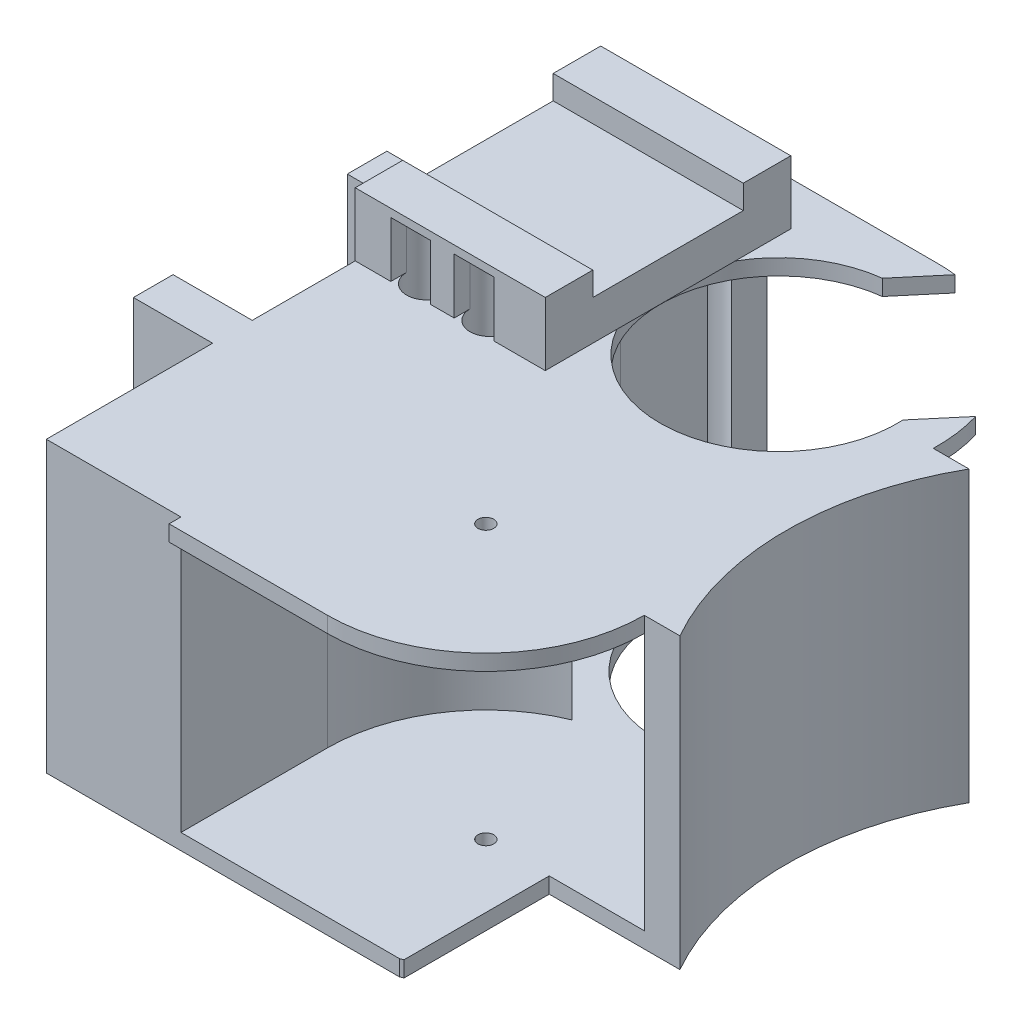
from build123d import *

# Parameters (mm, degrees)
SKETCH1_R                = 2
SKETCH1_R_2              = 1
BOSS_EXTRUDE18_DEPTH     = 34.5
CUT_EXTRUDE16_DEPTH      = 32.5
BOSS_EXTRUDE21_DEPTH     = 2
SKETCH9_R                = 2
BOSS_EXTRUDE22_DEPTH     = 34.5
SKETCH10_R               = 2
BOSS_EXTRUDE23_DEPTH     = 34.5
SKETCH11_R               = 2
CUT_EXTRUDE17_DEPTH      = 34.5
SKETCH12_W               = 24
SKETCH12_H               = 27
BOSS_EXTRUDE24_DEPTH     = 8
SKETCH13_W               = 24
SKETCH13_H               = 19
CUT_EXTRUDE18_DEPTH      = 3
SKETCH16_R               = 2.5
CUT_EXTRUDE21_DEPTH      = 41.5
SKETCH20_R               = 2.5
CUT_EXTRUDE22_DEPTH      = 41.5
SKETCH21_R               = 2.5
CUT_EXTRUDE23_DEPTH      = 41.5
SKETCH22_R               = 2.5
CUT_EXTRUDE24_DEPTH      = 41.5
BOSS_EXTRUDE25_DEPTH     = 2
BOSS_EXTRUDE26_DEPTH     = 2
SKETCH27_R               = 1
CUT_EXTRUDE27_DEPTH      = 5
SKETCH28_R               = 1
CUT_EXTRUDE28_DEPTH      = 5
SKETCH29_R               = 15
CUT_EXTRUDE29_DEPTH      = 2
SKETCH30_R               = 1
CUT_EXTRUDE30_DEPTH      = 2
CUT_EXTRUDE31_DEPTH      = 104.309002512
CUT_EXTRUDE31_DEPTH_BACK = 10
SKETCH32_R               = 2.5
SKETCH32_R_2             = 1
BOSS_EXTRUDE28_DEPTH     = 2
CUT_EXTRUDE32_DEPTH      = 2
SKETCH35_R               = 15
CUT_EXTRUDE33_DEPTH      = 2
BOSS_EXTRUDE30_START     = -2
SKETCH36_R               = 2.5
BOSS_EXTRUDE30_DEPTH     = 2
CUT_EXTRUDE40_START      = -2
CUT_EXTRUDE40_DEPTH      = 2
SKETCH39_R               = 2.5
CUT_EXTRUDE41_DEPTH      = 2
CUT_EXTRUDE42_START      = -2
CUT_EXTRUDE42_DEPTH      = 2
SKETCH42_R               = 1
BOSS_EXTRUDE31_DEPTH     = 5
SKETCH43_R               = 1
CUT_EXTRUDE44_DEPTH      = 5
SKETCH46_R               = 1
BOSS_EXTRUDE32_DEPTH     = 5
SKETCH47_R               = 1
CUT_EXTRUDE45_DEPTH      = 5
SKETCH48_R               = 1
BOSS_EXTRUDE33_DEPTH     = 5
SKETCH49_R               = 1
CUT_EXTRUDE46_DEPTH      = 5
SKETCH50_R               = 1
BOSS_EXTRUDE34_DEPTH     = 5
SKETCH51_R               = 1
CUT_EXTRUDE47_DEPTH      = 5


with BuildPart() as part:
    # Sketch1 → Boss-Extrude18 (new body)
    with BuildSketch(Plane(origin=(0, 0, 0), x_dir=(1, 0, 0), z_dir=(0, 1, 0))):
        with BuildLine():
            Line((0, 0), (17, 0))
            Line((17, 0), (17, 18.5))
            ThreePointArc((17, 18.5), (20.386950287, 29.635824138), (29.400657923, 37))
            ThreePointArc((29.400657923, 37), (20.386950287, 44.364175862), (17, 55.5))
            Line((17, 55.5), (17, 66.5))
            ThreePointArc((17, 66.5), (12.5, 68), (17, 69.5))
            Line((17, 69.5), (17, 74))
            Line((17, 74), (0, 74))
            Line((0, 74), (0, 53))
            Line((0, 53), (-10, 53))
            Line((-10, 53), (-10, 48))
            Line((-10, 48), (0, 48))
            Line((0, 48), (0, 26))
            Line((0, 26), (-10, 26))
            Line((-10, 26), (-10, 21))
            Line((-10, 21), (0, 21))
            Line((0, 21), (0, 0))
        make_face()
        with Locations(Location((7, 40, 0), (0, 0, 270))):
            Circle(SKETCH1_R, mode=Mode.SUBTRACT)
        with Locations(Location((15, 40, 0), (0, 0, 270))):
            Circle(SKETCH1_R, mode=Mode.SUBTRACT)
        with Locations(Location((7, 68, 0), (0, 0, 270))):
            Circle(SKETCH1_R, mode=Mode.SUBTRACT)
        with BuildLine():
            ThreePointArc((44.599342077, 37), (53.613049713, 29.635824138), (57, 18.5))
            Line((57, 18.5), (61.5, 18.5))
            ThreePointArc((61.5, 18.5), (56.685982974, 36.75), (61.5, 55))
            Line((61.5, 55), (56.993749023, 55))
            ThreePointArc((56.993749023, 55), (53.472542885, 44.157366669), (44.599342077, 37))
        make_face()
        with BuildLine():
            ThreePointArc((44.599342077, 0), (44.800132537, 0.083759004), (45, 0.16969722))
            Line((45, 0.16969722), (45, 18.5))
            Line((45, 18.5), (57, 18.5))
            ThreePointArc((57, 18.5), (53.613049713, 29.635824138), (44.599342077, 37))
            ThreePointArc((44.599342077, 37), (53.472542885, 44.157366669), (56.993749023, 55))
            Line((56.993749023, 55), (51.991664351, 55))
            ThreePointArc((51.991664351, 55), (36.749965261, 40.502084057), (22, 55.5))
            Line((22, 55.5), (22, 74))
            Line((22, 74), (17, 74))
            Line((17, 74), (17, 69.5))
            ThreePointArc((17, 69.5), (17.371708245, 68.790569415), (17.5, 68))
            ThreePointArc((17.5, 68), (17.371708245, 67.209430585), (17, 66.5))
            Line((17, 66.5), (17, 55.5))
            ThreePointArc((17, 55.5), (20.386950287, 44.364175862), (29.400657923, 37))
            ThreePointArc((29.400657923, 37), (20.386950287, 29.635824138), (17, 18.5))
            Line((17, 18.5), (17, 0))
            Line((17, 0), (44.599342077, 0))
        make_face()
        with Locations(Location((37, 18.5, 0), (0, 0, 270))):
            Circle(SKETCH1_R_2, mode=Mode.SUBTRACT)
    extrude(amount=BOSS_EXTRUDE18_DEPTH)

    # Sketch7 → Cut-Extrude16 (cut)
    with BuildSketch(Plane(origin=(0, 34.5, 0), x_dir=(1, 0, 0), z_dir=(0, 1, 0))):
        with BuildLine():
            Line((17, 55.5), (17, 75.5))
            Line((17, 75.5), (37, 75.5))
            ThreePointArc((37, 75.5), (56.62141687, 59.372983346), (44.599342077, 37))
            ThreePointArc((44.599342077, 37), (56.62141687, 14.627016654), (37, -1.5))
            Line((37, -1.5), (17, -1.5))
            Line((17, -1.5), (17, 18.5))
            ThreePointArc((17, 18.5), (20.386950287, 29.635824138), (29.400657923, 37))
            ThreePointArc((29.400657923, 37), (20.386950287, 44.364175862), (17, 55.5))
        make_face()
    extrude(amount=-CUT_EXTRUDE16_DEPTH, mode=Mode.SUBTRACT)

    # Sketch8 → Boss-Extrude21 (add)
    with BuildSketch(Plane(origin=(0, 34.5, 0), x_dir=(1, 0, 0), z_dir=(0, 1, 0))):
        with BuildLine():
            Line((17, 18.5), (17, -1.5))
            Line((17, -1.5), (37, -1.5))
            ThreePointArc((37, -1.5), (56.62141687, 14.627016654), (44.599342077, 37))
            ThreePointArc((44.599342077, 37), (56.62141687, 59.372983346), (37, 75.5))
            Line((37, 75.5), (17, 75.5))
            Line((17, 75.5), (17, 55.5))
            ThreePointArc((17, 55.5), (20.386950287, 44.364175862), (29.400657923, 37))
            ThreePointArc((29.400657923, 37), (20.386950287, 29.635824138), (17, 18.5))
        make_face()
    extrude(amount=-BOSS_EXTRUDE21_DEPTH)

    # Sketch9 → Boss-Extrude22 (add)
    with BuildSketch(Plane(origin=(0, 34.5, 0), x_dir=(1, 0, 0), z_dir=(0, 1, 0))):
        with Locations((7, 40)):
            Circle(SKETCH9_R)
    extrude(amount=-BOSS_EXTRUDE22_DEPTH)

    # Sketch10 → Boss-Extrude23 (add)
    with BuildSketch(Plane(origin=(0, 34.5, 0), x_dir=(1, 0, 0), z_dir=(0, 1, 0))):
        with Locations((15, 40)):
            Circle(SKETCH10_R)
    extrude(amount=-BOSS_EXTRUDE23_DEPTH)

    # Sketch11 → Cut-Extrude17 (cut)
    with BuildSketch(Plane(origin=(0, 34.5, 0), x_dir=(1, 0, 0), z_dir=(0, 1, 0))):
        with Locations(Location((7, 41, 0), (0, 0, 270))):
            Circle(SKETCH11_R)
        with Locations(Location((15, 41, 0), (0, 0, 270))):
            Circle(SKETCH11_R)
    extrude(amount=-CUT_EXTRUDE17_DEPTH, mode=Mode.SUBTRACT)

    # Sketch12 → Boss-Extrude24 (add)
    with BuildSketch(Plane(origin=(0, 34.5, 0), x_dir=(1, 0, 0), z_dir=(0, 1, 0))):
        with Locations((12, 54.5)):
            Rectangle(SKETCH12_W, SKETCH12_H)
    extrude(amount=BOSS_EXTRUDE24_DEPTH)

    # Sketch13 → Cut-Extrude18 (cut)
    with BuildSketch(Plane(origin=(0, 42.5, 0), x_dir=(1, 0, 0), z_dir=(0, 1, 0))):
        with Locations((12, 54.5)):
            Rectangle(SKETCH13_W, SKETCH13_H)
    extrude(amount=-CUT_EXTRUDE18_DEPTH, mode=Mode.SUBTRACT)

    # Sketch16 → Cut-Extrude21 (cut)
    with BuildSketch(Plane(origin=(0, 0, 0), x_dir=(-1, 0, 0), z_dir=(0, -1, 0))):
        with Locations(Location((-7, 68, 0), (0, 0, 90))):
            Circle(SKETCH16_R)
    extrude(amount=-CUT_EXTRUDE21_DEPTH, mode=Mode.SUBTRACT)

    # Sketch20 → Cut-Extrude22 (cut)
    with BuildSketch(Plane(origin=(0, 0, 0), x_dir=(-1, 0, 0), z_dir=(0, -1, 0))):
        with Locations((-15, 68)):
            Circle(SKETCH20_R)
    extrude(amount=-CUT_EXTRUDE22_DEPTH, mode=Mode.SUBTRACT)

    # Sketch21 → Cut-Extrude23 (cut)
    with BuildSketch(Plane(origin=(0, 0, 0), x_dir=(-1, 0, 0), z_dir=(0, -1, 0))):
        with Locations(Location((-7, 41, 0), (0, 0, 90))):
            Circle(SKETCH21_R)
    extrude(amount=-CUT_EXTRUDE23_DEPTH, mode=Mode.SUBTRACT)

    # Sketch22 → Cut-Extrude24 (cut)
    with BuildSketch(Plane(origin=(0, 0, 0), x_dir=(-1, 0, 0), z_dir=(0, -1, 0))):
        with Locations(Location((-15, 41, 0), (0, 0, 90))):
            Circle(SKETCH22_R)
    extrude(amount=-CUT_EXTRUDE24_DEPTH, mode=Mode.SUBTRACT)

    # Sketch23 → Boss-Extrude25 (add)
    with BuildSketch(Plane(origin=(0, 0, -68), x_dir=(-1, 0, 0), z_dir=(0, 0, -1))):
        Polygon((-24, 39.595178564), (-24, 42.5), (0, 42.5), (0, 34.5), (-4.5, 34.5), (-4.5, 41.5), (-9.5, 41.5), (-9.5, 34.5), (-12.5, 34.5), (-12.5, 41.5), (-17.5, 41.5), (-17.5, 34.5), (-24, 34.5), align=None)
    extrude(amount=BOSS_EXTRUDE25_DEPTH)

    # Sketch26 → Boss-Extrude26 (add)
    with BuildSketch(Plane.XY.offset(-41)):
        Polygon((19.87143218, 42.5), (24, 42.5), (24, 34.5), (17.5, 34.5), (17.5, 41.5), (12.5, 41.5), (12.5, 34.5), (9.5, 34.5), (9.5, 41.5), (4.5, 41.5), (4.5, 34.5), (0, 34.5), (0, 42.5), align=None)
    extrude(amount=BOSS_EXTRUDE26_DEPTH)

    # Sketch27 → Cut-Extrude27 (cut)
    with BuildSketch(Plane(origin=(0, 0, -53), x_dir=(-1, 0, 0), z_dir=(0, 0, -1))):
        with Locations((5, 8.75)):
            Circle(SKETCH27_R)
        with Locations((5, 25.75)):
            Circle(SKETCH27_R)
    extrude(amount=-CUT_EXTRUDE27_DEPTH, mode=Mode.SUBTRACT)

    # Sketch28 → Cut-Extrude28 (cut)
    with BuildSketch(Plane(origin=(0, 0, -26), x_dir=(-1, 0, 0), z_dir=(0, 0, -1))):
        with Locations((5, 8.75)):
            Circle(SKETCH28_R)
        with Locations((5, 25.75)):
            Circle(SKETCH28_R)
    extrude(amount=-CUT_EXTRUDE28_DEPTH, mode=Mode.SUBTRACT)

    # Sketch29 → Cut-Extrude29 (cut)
    with BuildSketch(Plane.XZ.offset(-32.5)):
        with Locations(Location((37, -55.5, 0), (0, 0, 270))):
            Circle(SKETCH29_R)
    extrude(amount=-CUT_EXTRUDE29_DEPTH, mode=Mode.SUBTRACT)

    # Sketch30 → Cut-Extrude30 (cut)
    with BuildSketch(Plane(origin=(0, 32.5, 0), x_dir=(-1, 0, 0), z_dir=(0, -1, 0))):
        with Locations(Location((-37, 18.5, 0), (0, 0, 270))):
            Circle(SKETCH30_R)
    extrude(amount=-CUT_EXTRUDE30_DEPTH, mode=Mode.SUBTRACT)

    # Sketch31 → Cut-Extrude31 (cut, two sides)
    with BuildSketch(Plane(origin=(0, 34.5, 0), x_dir=(1, 0, 0), z_dir=(0, 1, 0))) as cut_extrude31_sk:
        with BuildLine():
            ThreePointArc((37, 70.5), (47.358546152, 66.348987124), (51.98396451, 56.193402882))
            Line((51.98396451, 56.193402882), (56.181432658, 61.163271245))
            ThreePointArc((56.181432658, 61.163271245), (49.904855392, 70.779551934), (39.37392553, 75.358612177))
            Line((39.37392553, 75.358612177), (35.176457383, 70.388743813))
            ThreePointArc((35.176457383, 70.388743813), (36.086533304, 70.472160118), (37, 70.5))
        make_face()
    extrude(amount=CUT_EXTRUDE31_DEPTH, mode=Mode.SUBTRACT)
    extrude(cut_extrude31_sk.sketch, amount=-CUT_EXTRUDE31_DEPTH_BACK, mode=Mode.SUBTRACT)

    # Sketch32 → Boss-Extrude28 (add)
    with BuildSketch(Plane(origin=(0, 0, 0), x_dir=(-1, 0, 0), z_dir=(0, -1, 0))):
        Polygon((0, 74), (0, 53), (10, 53), (10, 48), (0, 48), (0, 26), (10, 26), (10, 21), (0, 21), (0, 0), (-44.599342077, 0), (-45, 0.16969722), (-45, 18.5), (-61.5, 18.5), (-61.5, 55), (-51.991664351, 55), (-22, 55.5), (-22, 74), align=None)
        with Locations(Location((-7, 68, 0), (0, 0, 90))):
            Circle(SKETCH32_R, mode=Mode.SUBTRACT)
        with Locations(Location((-7, 41, 0), (0, 0, 90))):
            Circle(SKETCH32_R, mode=Mode.SUBTRACT)
        with Locations(Location((-15, 68, 0), (0, 0, 90))):
            Circle(SKETCH32_R, mode=Mode.SUBTRACT)
        with Locations(Location((-15, 41, 0), (0, 0, 90))):
            Circle(SKETCH32_R, mode=Mode.SUBTRACT)
        with Locations(Location((-37, 18.5, 0), (0, 0, 90))):
            Circle(SKETCH32_R_2, mode=Mode.SUBTRACT)
    extrude(amount=BOSS_EXTRUDE28_DEPTH)

    # Sketch34 → Cut-Extrude32 (cut)
    with BuildSketch(Plane(origin=(0, -2, 0), x_dir=(-1, 0, 0), z_dir=(0, -1, 0))):
        with BuildLine():
            Line((-61.5, 55), (-61.5, 18.5))
            ThreePointArc((-61.5, 18.5), (-56.685982974, 36.75), (-61.5, 55))
        make_face()
    extrude(amount=-CUT_EXTRUDE32_DEPTH, mode=Mode.SUBTRACT)

    # Sketch35 → Cut-Extrude33 (cut)
    with BuildSketch(Plane(origin=(0, -2, 0), x_dir=(-1, 0, 0), z_dir=(0, -1, 0))):
        with Locations((-36.996772278, 55.249984327)):
            Circle(SKETCH35_R)
    extrude(amount=-CUT_EXTRUDE33_DEPTH, mode=Mode.SUBTRACT)

    # Sketch36 → Boss-Extrude30 (add)
    with BuildSketch(Plane(origin=(0, -2, 0), x_dir=(-1, 0, 0), z_dir=(0, -1, 0)).offset(BOSS_EXTRUDE30_START)):
        with Locations(Location((-15, 68, 0), (0, 0, 143.130102354))):
            Circle(SKETCH36_R)
    extrude(amount=-BOSS_EXTRUDE30_DEPTH)

    # Sketch38 → Cut-Extrude40 (cut)
    with BuildSketch(Plane.XZ.offset(2).offset(CUT_EXTRUDE40_START)):
        with BuildLine():
            Line((17, -75.5), (57, -75.5))
            Line((57, -75.5), (57, -55.5))
            ThreePointArc((57, -55.5), (37, -35.5), (17, -55.5))
            Line((17, -55.5), (17, -75.5))
        make_face()
    extrude(amount=-CUT_EXTRUDE40_DEPTH, mode=Mode.SUBTRACT)

    # Sketch39 → Cut-Extrude41 (cut)
    with BuildSketch(Plane(origin=(0, 0, 0), x_dir=(-1, 0, 0), z_dir=(0, -1, 0))):
        with Locations(Location((-15, 68, 0), (0, 0, 90))):
            Circle(SKETCH39_R)
    extrude(amount=-CUT_EXTRUDE41_DEPTH, mode=Mode.SUBTRACT)

    # Sketch41 → Cut-Extrude42 (cut)
    with BuildSketch(Plane(origin=(0, -2, 0), x_dir=(-1, 0, 0), z_dir=(0, -1, 0)).offset(CUT_EXTRUDE42_START)):
        with BuildLine():
            Line((-17, 18.5), (-17, -1.5))
            Line((-17, -1.5), (-37, -1.5))
            Line((-37, -1.5), (-57, -1.5))
            Line((-57, -1.5), (-57, 18.5))
            ThreePointArc((-57, 18.5), (-37, 38.5), (-17, 18.5))
        make_face()
    extrude(amount=-CUT_EXTRUDE42_DEPTH, mode=Mode.SUBTRACT)

    # Sketch42 → Boss-Extrude31 (add)
    with BuildSketch(Plane(origin=(0, 0, -26), x_dir=(-1, 0, 0), z_dir=(0, 0, -1))):
        with Locations((5, 8.75)):
            Circle(SKETCH42_R)
    extrude(amount=-BOSS_EXTRUDE31_DEPTH)

    # Sketch43 → Cut-Extrude44 (cut)
    with BuildSketch(Plane(origin=(0, 0, -26), x_dir=(-1, 0, 0), z_dir=(0, 0, -1))):
        with Locations((5, 8.25)):
            Circle(SKETCH43_R)
    extrude(amount=-CUT_EXTRUDE44_DEPTH, mode=Mode.SUBTRACT)

    # Sketch46 → Boss-Extrude32 (add)
    with BuildSketch(Plane(origin=(0, 0, -26), x_dir=(-1, 0, 0), z_dir=(0, 0, -1))):
        with Locations((5, 25.75)):
            Circle(SKETCH46_R)
    extrude(amount=-BOSS_EXTRUDE32_DEPTH)

    # Sketch47 → Cut-Extrude45 (cut)
    with BuildSketch(Plane(origin=(0, 0, -26), x_dir=(-1, 0, 0), z_dir=(0, 0, -1))):
        with Locations((5, 24.25)):
            Circle(SKETCH47_R)
    extrude(amount=-CUT_EXTRUDE45_DEPTH, mode=Mode.SUBTRACT)

    # Sketch48 → Boss-Extrude33 (add)
    with BuildSketch(Plane(origin=(0, 0, -53), x_dir=(-1, 0, 0), z_dir=(0, 0, -1))):
        with Locations((5, 8.75)):
            Circle(SKETCH48_R)
    extrude(amount=-BOSS_EXTRUDE33_DEPTH)

    # Sketch49 → Cut-Extrude46 (cut)
    with BuildSketch(Plane(origin=(0, 0, -53), x_dir=(-1, 0, 0), z_dir=(0, 0, -1))):
        with Locations((5, 8.25)):
            Circle(SKETCH49_R)
    extrude(amount=-CUT_EXTRUDE46_DEPTH, mode=Mode.SUBTRACT)

    # Sketch50 → Boss-Extrude34 (add)
    with BuildSketch(Plane(origin=(0, 0, -53), x_dir=(-1, 0, 0), z_dir=(0, 0, -1))):
        with Locations((5, 25.75)):
            Circle(SKETCH50_R)
    extrude(amount=-BOSS_EXTRUDE34_DEPTH)

    # Sketch51 → Cut-Extrude47 (cut)
    with BuildSketch(Plane(origin=(0, 0, -53), x_dir=(-1, 0, 0), z_dir=(0, 0, -1))):
        with Locations((5, 24.25)):
            Circle(SKETCH51_R)
    extrude(amount=-CUT_EXTRUDE47_DEPTH, mode=Mode.SUBTRACT)


solid = part.part
